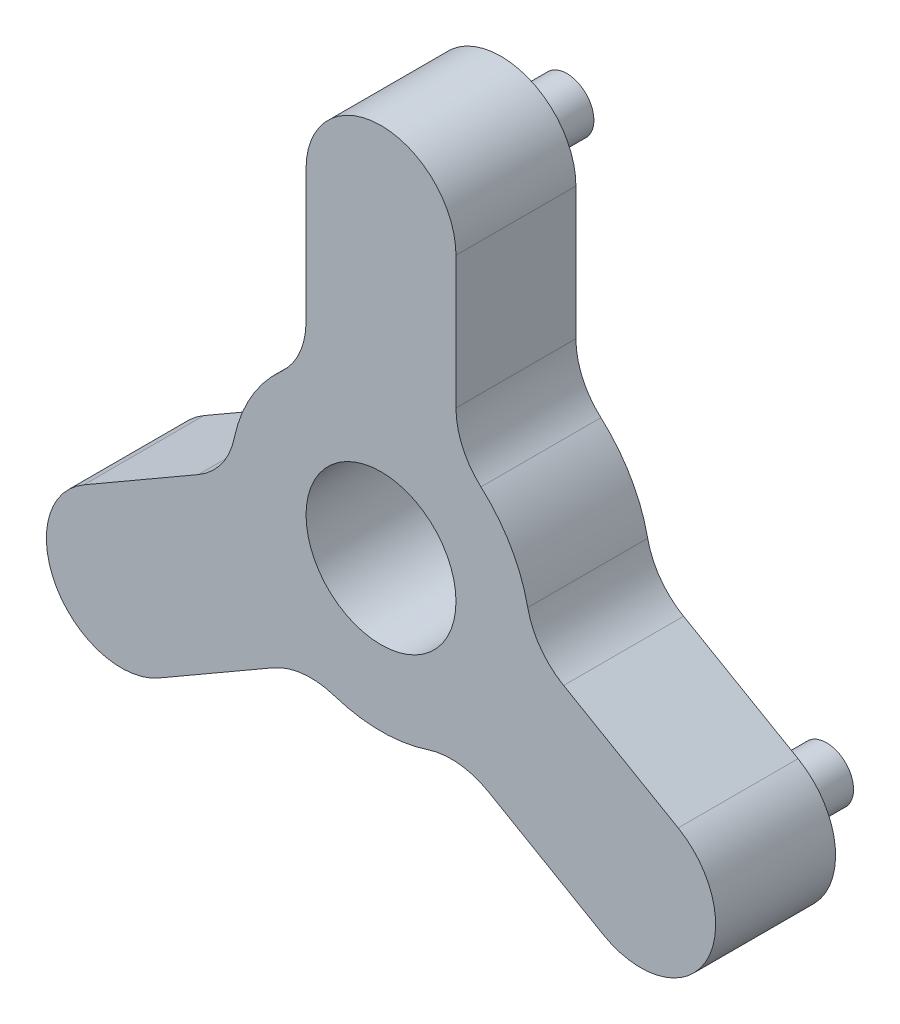
from build123d import *

# Parameters (mm, degrees)
BOSS_EXTRUDE1_DEPTH = 10.16
SKETCH2_R           = 2.2857079
BOSS_EXTRUDE2_DEPTH = 5.588
SKETCH3_R           = 6.35
CUT_EXTRUDE1_DEPTH  = 10.16
SCALE1_SCALE        = 1.75


with BuildPart() as part:
    # Sketch1 → Boss-Extrude1 (new body)
    with BuildSketch(Plane.XY):
        with BuildLine():
            Line((-6.35, 25.4), (-6.35, 14.199031657))
            ThreePointArc((-6.35, 14.199031657), (-6.9032696, 11.606655013), (-8.466666667, 9.466021105))
            ThreePointArc((-8.466666667, 9.466021105), (-10.998522628, 6.35), (-12.431148083, 2.599337866))
            ThreePointArc((-12.431148083, 2.599337866), (-13.503292894, 0.175079336), (-15.471722124, -1.600254515))
            Line((-15.471722124, -1.600254515), (-25.172045256, -7.200738686))
            ThreePointArc((-25.172045256, -7.200738686), (-27.49630657, -15.875), (-18.822045256, -18.199261314))
            Line((-18.822045256, -18.199261314), (-9.121722124, -12.598777143))
            ThreePointArc((-9.121722124, -12.598777143), (-6.600023294, -11.781734349), (-3.964481416, -12.065358971))
            ThreePointArc((-3.964481416, -12.065358971), (0, -12.7), (3.964481416, -12.065358971))
            ThreePointArc((3.964481416, -12.065358971), (6.600023294, -11.781734349), (9.121722124, -12.598777143))
            Line((9.121722124, -12.598777143), (18.822045256, -18.199261314))
            ThreePointArc((18.822045256, -18.199261314), (27.49630657, -15.875), (25.172045256, -7.200738686))
            Line((25.172045256, -7.200738686), (15.471722124, -1.600254515))
            ThreePointArc((15.471722124, -1.600254515), (13.503292894, 0.175079336), (12.431148083, 2.599337866))
            ThreePointArc((12.431148083, 2.599337866), (10.998522628, 6.35), (8.466666667, 9.466021105))
            ThreePointArc((8.466666667, 9.466021105), (6.9032696, 11.606655013), (6.35, 14.199031657))
            Line((6.35, 14.199031657), (6.35, 25.4))
            ThreePointArc((6.35, 25.4), (0, 31.75), (-6.35, 25.4))
        make_face()
    extrude(amount=BOSS_EXTRUDE1_DEPTH)

    # Sketch2 → Boss-Extrude2 (add)
    with BuildSketch(Plane(origin=(0, 0, 0), x_dir=(-1, 0, 0), z_dir=(0, 0, -1))):
        with Locations((0, 25.4)):
            Circle(SKETCH2_R)
        with Locations((21.997045256, -12.7)):
            Circle(SKETCH2_R)
        with Locations((-21.997045256, -12.7)):
            Circle(SKETCH2_R)
    extrude(amount=BOSS_EXTRUDE2_DEPTH)

    # Sketch3 → Cut-Extrude1 (cut)
    with BuildSketch(Plane(origin=(0, 0, 0), x_dir=(-1, 0, 0), z_dir=(0, 0, -1))):
        Circle(SKETCH3_R)
    extrude(amount=-CUT_EXTRUDE1_DEPTH, mode=Mode.SUBTRACT)


with BuildPart() as part_1:
    # Scale1: scaled about (0, 0, 4.887896588)
    add(part.part.scale(SCALE1_SCALE).moved(Location((0, 0, -3.665922441))))


solid = part_1.part
